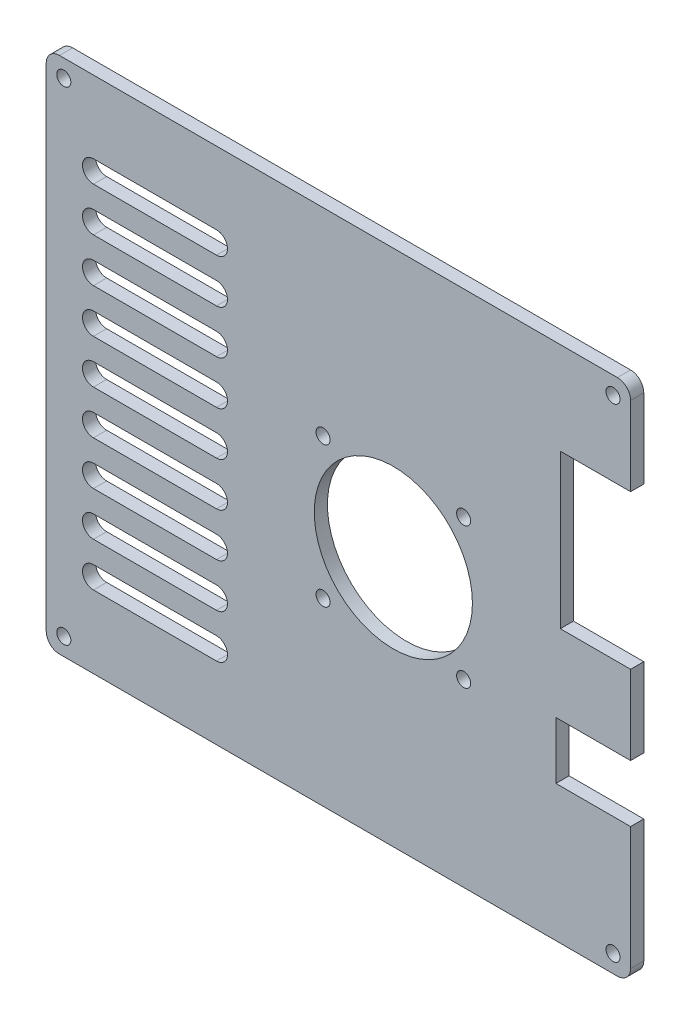
from build123d import *

# Parameters (mm, degrees)
SKETCH1_R           = 18
SKETCH1_R_2         = 1.6
BOSS_EXTRUDE1_DEPTH = 3


with BuildPart() as part:
    # Sketch1 → Boss-Extrude1 (new body)
    with BuildSketch(Plane.XY):
        with BuildLine():
            Line((-63.5, -59), (63.5, -59))
            ThreePointArc((63.5, -59), (65.621320344, -58.121320344), (66.5, -56))
            Line((66.5, -56), (66.5, -28))
            Line((66.5, -28), (49.5, -28))
            Line((49.5, -28), (49.5, -15))
            Line((49.5, -15), (66.5, -15))
            Line((66.5, -15), (66.5, 3))
            Line((66.5, 3), (50.5, 3))
            Line((50.5, 3), (50.5, 38))
            Line((50.5, 38), (66.5, 38))
            Line((66.5, 38), (66.5, 56))
            ThreePointArc((66.5, 56), (65.621320344, 58.121320344), (63.5, 59))
            Line((63.5, 59), (-63.5, 59))
            ThreePointArc((-63.5, 59), (-65.621320344, 58.121320344), (-66.5, 56))
            Line((-66.5, 56), (-66.5, -56))
            ThreePointArc((-66.5, -56), (-65.621320344, -58.121320344), (-63.5, -59))
        make_face()
        with Locations((12.5, -2)):
            Circle(SKETCH1_R, mode=Mode.SUBTRACT)
        with Locations((-3.5, 14)):
            Circle(SKETCH1_R_2, mode=Mode.SUBTRACT)
        with Locations((28.5, 14)):
            Circle(SKETCH1_R_2, mode=Mode.SUBTRACT)
        with Locations((28.5, -18)):
            Circle(SKETCH1_R_2, mode=Mode.SUBTRACT)
        with Locations((-3.5, -18)):
            Circle(SKETCH1_R_2, mode=Mode.SUBTRACT)
        with Locations((-62.5, 55)):
            Circle(SKETCH1_R_2, mode=Mode.SUBTRACT)
        with Locations((62.5, 55)):
            Circle(SKETCH1_R_2, mode=Mode.SUBTRACT)
        with Locations((-62.5, -55)):
            Circle(SKETCH1_R_2, mode=Mode.SUBTRACT)
        with Locations((62.5, -55)):
            Circle(SKETCH1_R_2, mode=Mode.SUBTRACT)
        with BuildLine():
            Line((-55.75, 2.5), (-27.75, 2.5))
            ThreePointArc((-27.75, 2.5), (-25.25, 0), (-27.75, -2.5))
            Line((-27.75, -2.5), (-55.75, -2.5))
            ThreePointArc((-55.75, -2.5), (-58.25, 0), (-55.75, 2.5))
        make_face(mode=Mode.SUBTRACT)
        with BuildLine():
            Line((-55.75, 12.5), (-27.75, 12.5))
            ThreePointArc((-27.75, 12.5), (-25.25, 10), (-27.75, 7.5))
            Line((-27.75, 7.5), (-55.75, 7.5))
            ThreePointArc((-55.75, 7.5), (-58.25, 10), (-55.75, 12.5))
        make_face(mode=Mode.SUBTRACT)
        with BuildLine():
            Line((-55.75, 22.5), (-27.75, 22.5))
            ThreePointArc((-27.75, 22.5), (-25.25, 20), (-27.75, 17.5))
            Line((-27.75, 17.5), (-55.75, 17.5))
            ThreePointArc((-55.75, 17.5), (-58.25, 20), (-55.75, 22.5))
        make_face(mode=Mode.SUBTRACT)
        with BuildLine():
            Line((-55.75, 32.5), (-27.75, 32.5))
            ThreePointArc((-27.75, 32.5), (-25.25, 30), (-27.75, 27.5))
            Line((-27.75, 27.5), (-55.75, 27.5))
            ThreePointArc((-55.75, 27.5), (-58.25, 30), (-55.75, 32.5))
        make_face(mode=Mode.SUBTRACT)
        with BuildLine():
            Line((-55.75, 42.5), (-27.75, 42.5))
            ThreePointArc((-27.75, 42.5), (-25.25, 40), (-27.75, 37.5))
            Line((-27.75, 37.5), (-55.75, 37.5))
            ThreePointArc((-55.75, 37.5), (-58.25, 40), (-55.75, 42.5))
        make_face(mode=Mode.SUBTRACT)
        with BuildLine():
            Line((-55.75, -37.5), (-27.75, -37.5))
            ThreePointArc((-27.75, -37.5), (-25.25, -40), (-27.75, -42.5))
            Line((-27.75, -42.5), (-55.75, -42.5))
            ThreePointArc((-55.75, -42.5), (-58.25, -40), (-55.75, -37.5))
        make_face(mode=Mode.SUBTRACT)
        with BuildLine():
            Line((-55.75, -27.5), (-27.75, -27.5))
            ThreePointArc((-27.75, -27.5), (-25.25, -30), (-27.75, -32.5))
            Line((-27.75, -32.5), (-55.75, -32.5))
            ThreePointArc((-55.75, -32.5), (-58.25, -30), (-55.75, -27.5))
        make_face(mode=Mode.SUBTRACT)
        with BuildLine():
            Line((-55.75, -17.5), (-27.75, -17.5))
            ThreePointArc((-27.75, -17.5), (-25.25, -20), (-27.75, -22.5))
            Line((-27.75, -22.5), (-55.75, -22.5))
            ThreePointArc((-55.75, -22.5), (-58.25, -20), (-55.75, -17.5))
        make_face(mode=Mode.SUBTRACT)
        with BuildLine():
            Line((-55.75, -7.5), (-27.75, -7.5))
            ThreePointArc((-27.75, -7.5), (-25.25, -10), (-27.75, -12.5))
            Line((-27.75, -12.5), (-55.75, -12.5))
            ThreePointArc((-55.75, -12.5), (-58.25, -10), (-55.75, -7.5))
        make_face(mode=Mode.SUBTRACT)
    extrude(amount=BOSS_EXTRUDE1_DEPTH)


solid = part.part
